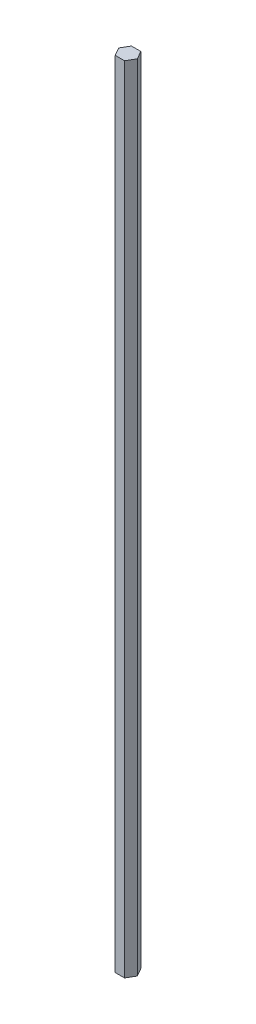
from build123d import *

# Parameters (mm, degrees)
BOSS_EXTRUDE1_DEPTH = 622.3


with BuildPart() as part:
    # Sketch1 → Boss-Extrude1 (new body)
    with BuildSketch(Plane(origin=(0, 0, 0), x_dir=(1, 0, 0), z_dir=(0, 1, 0))):
        Polygon((3.666174209, -6.35), (7.332348419, 0), (3.666174209, 6.35), (-3.666174209, 6.35), (-7.332348419, 0), (-3.666174209, -6.35), align=None)
    extrude(amount=BOSS_EXTRUDE1_DEPTH)


solid = part.part
